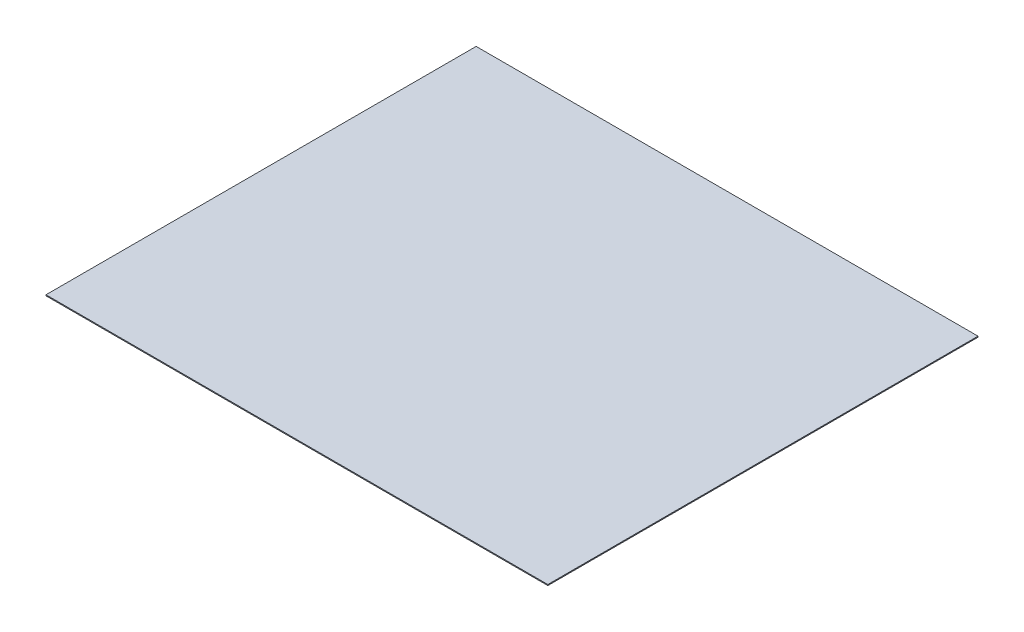
from build123d import *

# Parameters (mm, degrees)
SKETCH1_W           = 266.7
SKETCH1_H           = 228.6
BOSS_EXTRUDE1_DEPTH = 0.508


with BuildPart() as part:
    # Sketch1 → Boss-Extrude1 (new body)
    with BuildSketch(Plane(origin=(0, 0, 0), x_dir=(1, 0, 0), z_dir=(0, 1, 0))):
        Rectangle(SKETCH1_W, SKETCH1_H)
    extrude(amount=BOSS_EXTRUDE1_DEPTH)


solid = part.part
